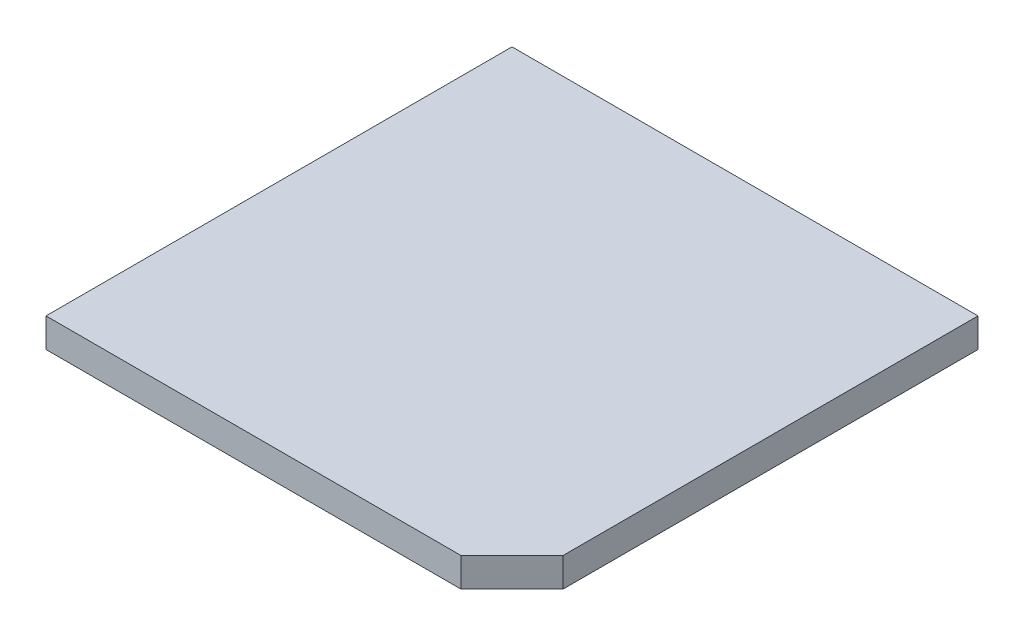
from build123d import *

# Parameters (mm, degrees)
SKETCH1_W           = 3.2
SKETCH1_H           = 3.2
BOSS_EXTRUDE1_DEPTH = 0.2
CHAMFER1_SIZE       = 0.35


with BuildPart() as part:
    # Sketch1 → Boss-Extrude1 (new body)
    with BuildSketch(Plane(origin=(0, 0, 0), x_dir=(1, 0, 0), z_dir=(0, 1, 0))):
        Rectangle(SKETCH1_W, SKETCH1_H)
    extrude(amount=BOSS_EXTRUDE1_DEPTH)

    # Chamfer1
    chamfer1_edges = [part.edges().sort_by_distance(p)[0] for p in [
        (1.6, 0.1, 1.6),
    ]]
    chamfer(chamfer1_edges, length=CHAMFER1_SIZE)


solid = part.part
